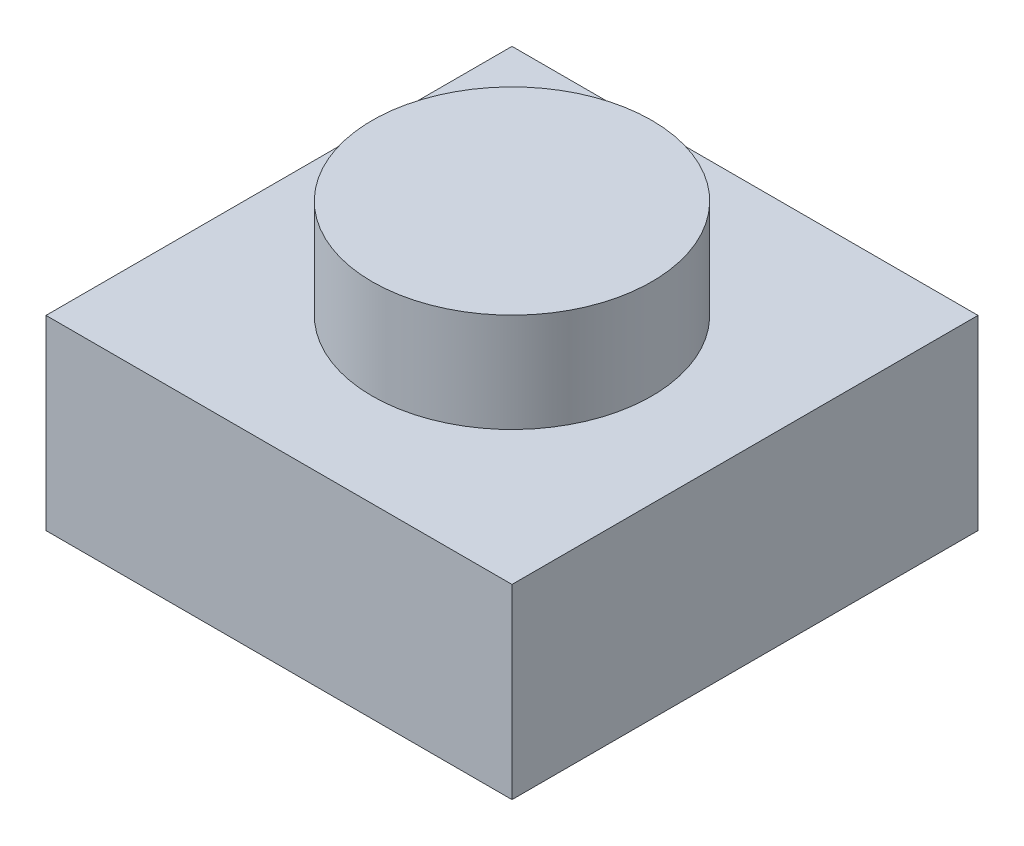
from build123d import *

# Parameters (mm, degrees)
SKETCH_1_W      = 8
SKETCH_1_H      = 8
HEIGHT_DEPTH    = 3.2
SKETCH_2_R      = 2.4
EXTRUDE_2_DEPTH = 1.7
SHELL_1_T       = -1.6


with BuildPart() as part:
    # 草圖1 → height (new body)
    with BuildSketch(Plane(origin=(0, 0, 0), x_dir=(1, 0, 0), z_dir=(0, 1, 0))):
        Rectangle(SKETCH_1_W, SKETCH_1_H)
    extrude(amount=HEIGHT_DEPTH)

    # 草圖2 → 填料-伸長2 (add)
    with BuildSketch(Plane(origin=(0, 3.2, 0), x_dir=(1, 0, 0), z_dir=(0, 1, 0))):
        Circle(SKETCH_2_R)
    extrude(amount=EXTRUDE_2_DEPTH)

    # 薄殼1
    shell_1_openings = [part.faces().sort_by_distance(p)[0] for p in [
        (0, 0, 0),
    ]]
    offset(amount=SHELL_1_T, openings=shell_1_openings, kind=Kind.INTERSECTION)


solid = part.part
